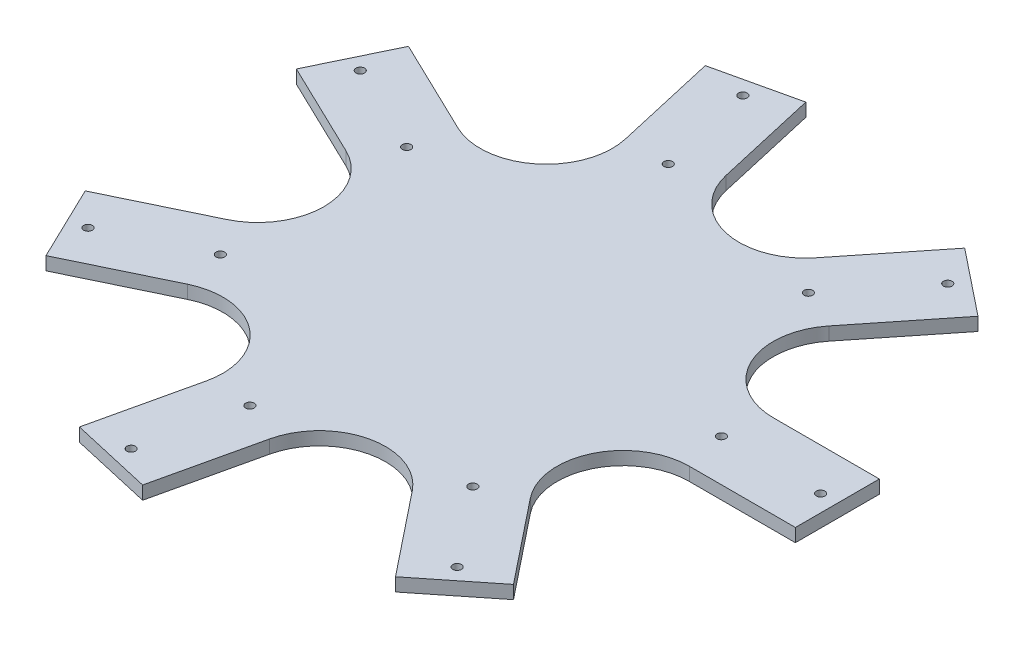
from build123d import *

# Parameters (mm, degrees)
SKETCH3_W           = 250
SKETCH3_H           = 63.5
SKETCH3_R           = 3.25
BOSS_EXTRUDE1_DEPTH = 10
CIRPATTERN1_COUNT   = 7
FILLET1_R           = 50


with BuildPart() as part:
    # Sketch3 → Boss-Extrude1 (new body)
    with BuildSketch(Plane(origin=(0, 0, 0), x_dir=(1, 0, 0), z_dir=(0, 1, 0))):
        with Locations((125, 0)):
            Rectangle(SKETCH3_W, SKETCH3_H)
        with Locations((162.3, 0)):
            Circle(SKETCH3_R, mode=Mode.SUBTRACT)
        with Locations((237.3, 0)):
            Circle(SKETCH3_R, mode=Mode.SUBTRACT)
    boss_extrude1 = extrude(amount=BOSS_EXTRUDE1_DEPTH)

    # CirPattern1: Boss-Extrude1 ×7 about axis
    cirpattern1_axis = Axis((0, 0, 0), (0, 1, 0))
    for i in range(1, CIRPATTERN1_COUNT):
        add(boss_extrude1.rotate(cirpattern1_axis, i * 360 / CIRPATTERN1_COUNT))

    # Fillet1
    fillet1_edges = [part.edges().sort_by_distance(p)[0] for p in [
        (65.929554341, 5, 31.75),
        (65.929554341, 5, -31.75),
        (16.283255204, 5, 71.341602418),
        (-45.624667219, 5, 57.211523112),
        (-73.176284653, 5, 0),
        (-45.624667219, 5, -57.211523112),
        (16.283255204, 5, -71.341602418),
    ]]
    fillet(fillet1_edges, radius=FILLET1_R)


solid = part.part
